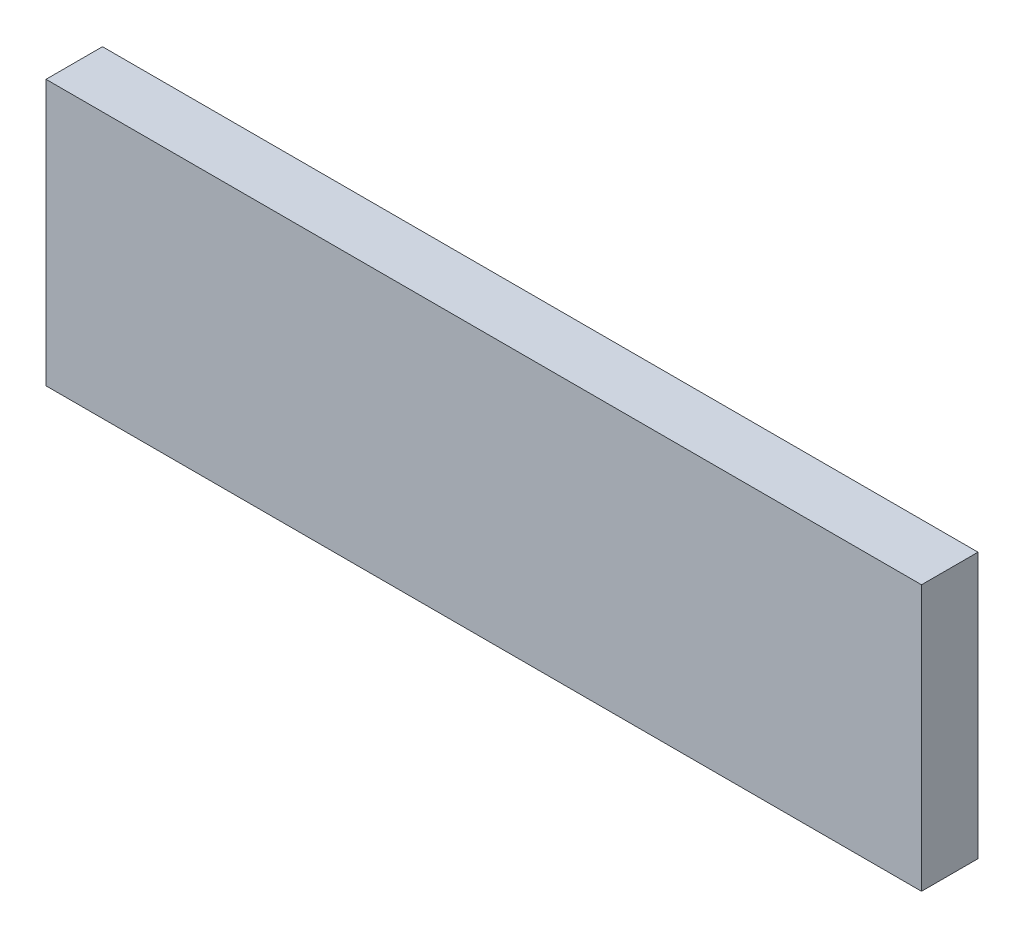
from build123d import *

# Parameters (mm, degrees)
SKETCH1_W           = 155
SKETCH1_H           = 47
BOSS_EXTRUDE1_DEPTH = 10


with BuildPart() as part:
    # Sketch1 → Boss-Extrude1 (new body)
    with BuildSketch(Plane.XY):
        with Locations((77.5, 23.5)):
            Rectangle(SKETCH1_W, SKETCH1_H)
    extrude(amount=BOSS_EXTRUDE1_DEPTH)


solid = part.part
